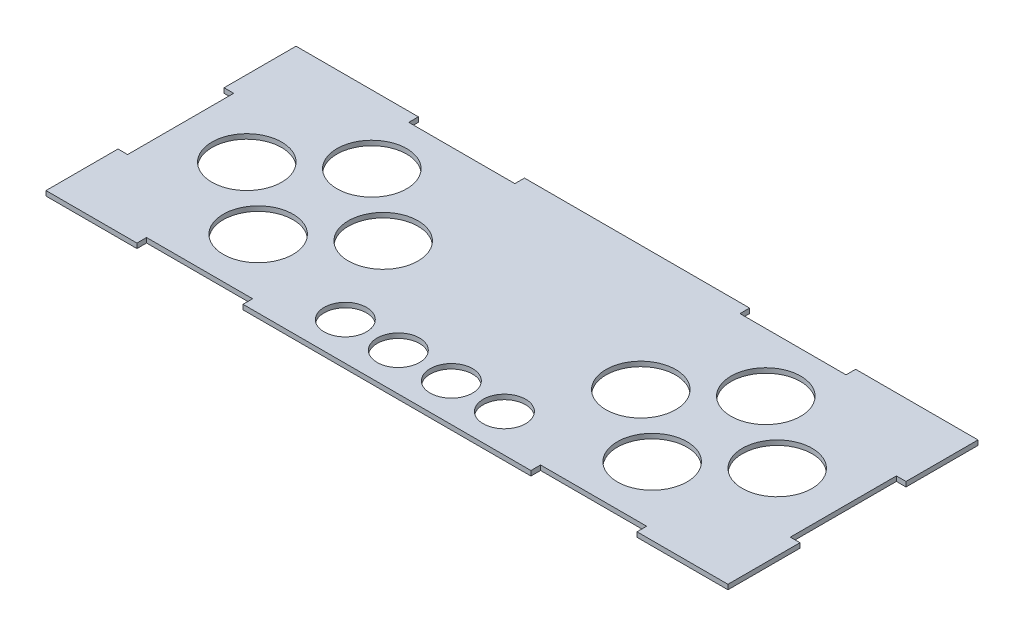
from build123d import *

# Parameters (mm, degrees)
SKETCH1_R           = 23
SKETCH1_R_2         = 14
BOSS_EXTRUDE1_DEPTH = 3.175


with BuildPart() as part:
    # Sketch1 → Boss-Extrude1 (new body)
    with BuildSketch(Plane(origin=(0, 0, 0), x_dir=(1, 0, 0), z_dir=(0, 1, 0))):
        Polygon((74.275, 82.5), (-74.275, 82.5), (-74.275, 76.15), (-144.275, 76.15), (-144.275, 82.5), (-225, 82.5), (-225, 35), (-218.65, 35), (-218.65, -35), (-225, -35), (-225, -82.5), (-165, -82.5), (-165, -76.15), (-95, -76.15), (-95, -82.5), (95, -82.5), (95, -76.15), (165, -76.15), (165, -82.5), (225, -82.5), (225, -35), (218.65, -35), (218.65, 35), (225, 35), (225, 82.5), (144.275, 82.5), (144.275, 76.15), (74.275, 76.15), align=None)
        with Locations(Location((-130, 37.5, 0), (0, 0, 270))):  # turned: the seam where the file's is
            Circle(SKETCH1_R, mode=Mode.SUBTRACT)
        with Locations(Location((-85, 0, 0), (0, 0, 270))):  # turned: the seam where the file's is
            Circle(SKETCH1_R, mode=Mode.SUBTRACT)
        with Locations(Location((-175, 0, 0), (0, 0, 270))):  # turned: the seam where the file's is
            Circle(SKETCH1_R, mode=Mode.SUBTRACT)
        with Locations(Location((-130, -37.5, 0), (0, 0, 270))):  # turned: the seam where the file's is
            Circle(SKETCH1_R, mode=Mode.SUBTRACT)
        with Locations(Location((130, 37.5, 0), (0, 0, 270))):  # turned: the seam where the file's is
            Circle(SKETCH1_R, mode=Mode.SUBTRACT)
        with Locations(Location((85, 0, 0), (0, 0, 270))):  # turned: the seam where the file's is
            Circle(SKETCH1_R, mode=Mode.SUBTRACT)
        with Locations(Location((175, 0, 0), (0, 0, 270))):  # turned: the seam where the file's is
            Circle(SKETCH1_R, mode=Mode.SUBTRACT)
        with Locations(Location((130, -37.5, 0), (0, 0, 270))):  # turned: the seam where the file's is
            Circle(SKETCH1_R, mode=Mode.SUBTRACT)
        with Locations(Location((-52.5, -57.5, 0), (0, 0, 270))):  # turned: the seam where the file's is
            Circle(SKETCH1_R_2, mode=Mode.SUBTRACT)
        with Locations(Location((-17.5, -57.5, 0), (0, 0, 270))):  # turned: the seam where the file's is
            Circle(SKETCH1_R_2, mode=Mode.SUBTRACT)
        with Locations(Location((17.5, -57.5, 0), (0, 0, 270))):  # turned: the seam where the file's is
            Circle(SKETCH1_R_2, mode=Mode.SUBTRACT)
        with Locations(Location((52.5, -57.5, 0), (0, 0, 270))):  # turned: the seam where the file's is
            Circle(SKETCH1_R_2, mode=Mode.SUBTRACT)
    extrude(amount=BOSS_EXTRUDE1_DEPTH)


solid = part.part
